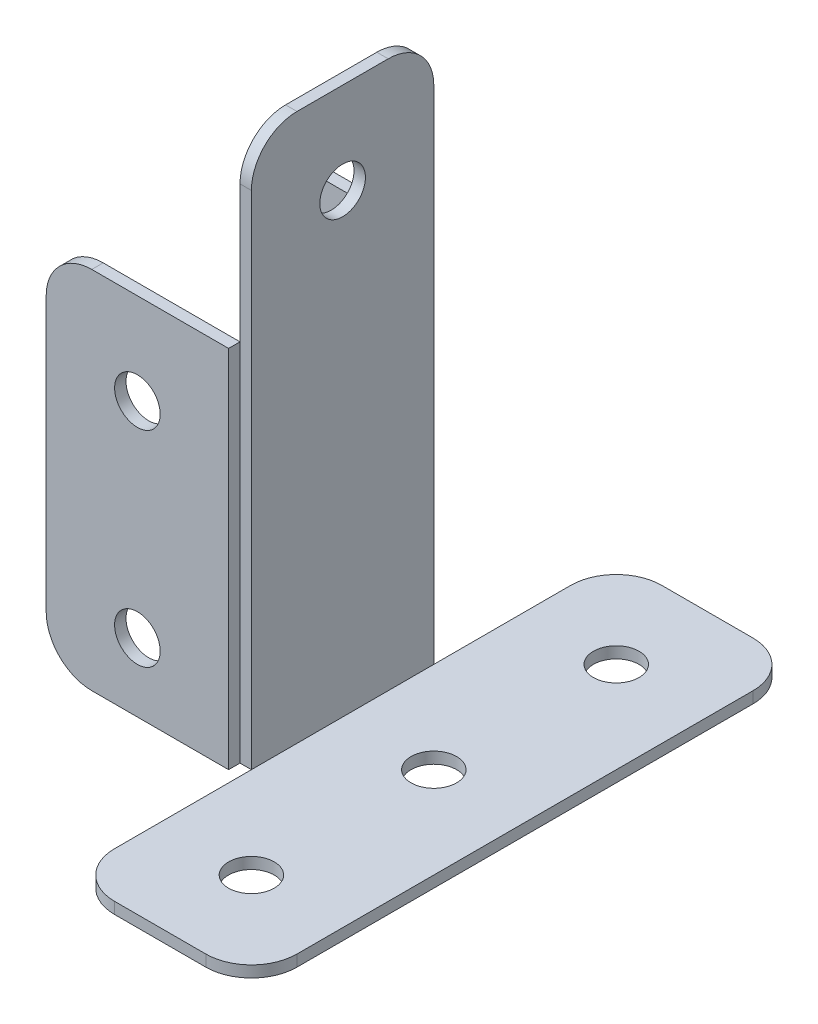
from build123d import *

# Parameters (mm, degrees)
SKETCH1_W           = 25.4
SKETCH1_H           = 50.8
SKETCH1_R           = 3.175
BOSS_EXTRUDE1_DEPTH = 1.5875
BOSS_EXTRUDE2_START = -25.4
SKETCH1_2_W         = 25.4
SKETCH1_2_H         = 50.8
SKETCH1_2_R         = 3.175
BOSS_EXTRUDE2_DEPTH = 1.5875
SKETCH3_R           = 3.175
BOSS_EXTRUDE3_DEPTH = 1.5875
SKETCH4_W           = 25.4
SKETCH4_H           = 76.2
SKETCH4_R           = 3.175
BOSS_EXTRUDE4_DEPTH = 1.5875
FILLET1_R           = 6.35
FILLET2_R           = 6.35
FILLET3_R           = 6.35
FILLET4_R           = 6.35


with BuildPart() as part:
    # Sketch1 → Boss-Extrude1 (new body)
    with BuildSketch(Plane.XY):
        with Locations((-12.7, 25.4)):
            Rectangle(SKETCH1_W, SKETCH1_H)
        with Locations((-12.7, 38.1)):
            Circle(SKETCH1_R, mode=Mode.SUBTRACT)
        with Locations((-12.7, 9.525)):
            Circle(SKETCH1_R, mode=Mode.SUBTRACT)
    extrude(amount=BOSS_EXTRUDE1_DEPTH)

    # Fillet3
    fillet3_edges = [part.edges().sort_by_distance(p)[0] for p in [
        (-25.4, 50.8, 0.79375),
        (-25.4, 0, 0.79375),
    ]]
    fillet(fillet3_edges, radius=FILLET3_R)


with BuildPart() as body_2:
    # Sketch1_2 → Boss-Extrude2 (new body)
    with BuildSketch(Plane.XY.offset(BOSS_EXTRUDE2_START)):
        with Locations((-12.7, 25.4)):
            Rectangle(SKETCH1_2_W, SKETCH1_2_H)
        with Locations((-12.7, 38.1)):
            Circle(SKETCH1_2_R, mode=Mode.SUBTRACT)
        with Locations((-12.7, 9.525)):
            Circle(SKETCH1_2_R, mode=Mode.SUBTRACT)
    extrude(amount=-BOSS_EXTRUDE2_DEPTH)

    # Fillet2
    fillet2_edges = [body_2.edges().sort_by_distance(p)[0] for p in [
        (-25.4, 0, -26.19375),
        (-25.4, 50.8, -26.19375),
    ]]
    fillet(fillet2_edges, radius=FILLET2_R)


with BuildPart() as body_3:
    # Sketch3 → Boss-Extrude3 (new body)
    with BuildSketch(Plane(origin=(0, 0, 0), x_dir=(0, 0, -1), z_dir=(1, 0, 0))):
        Polygon((25.4, 50.8), (25.4, 0), (0, 0), (0, 50.8), (0, 76.2), (25.4, 76.2), align=None)
        with Locations((12.7, 63.5)):
            Circle(SKETCH3_R, mode=Mode.SUBTRACT)
    extrude(amount=BOSS_EXTRUDE3_DEPTH)

    # Fillet4
    fillet4_edges = [body_3.edges().sort_by_distance(p)[0] for p in [
        (0.79375, 76.2, -25.4),
        (0.79375, 76.2, 0),
    ]]
    fillet(fillet4_edges, radius=FILLET4_R)


with BuildPart() as body_4:
    # Sketch4 → Boss-Extrude4 (new body)
    with BuildSketch(Plane(origin=(0, 0, 0), x_dir=(1, 0, 0), z_dir=(0, 1, 0))):
        with Locations((14.2875, 12.7)):
            Rectangle(SKETCH4_W, SKETCH4_H)
        with Locations((14.2875, 38.1)):
            Circle(SKETCH4_R, mode=Mode.SUBTRACT)
        with Locations((14.2875, 12.7)):
            Circle(SKETCH4_R, mode=Mode.SUBTRACT)
        with Locations((14.2875, -12.7)):
            Circle(SKETCH4_R, mode=Mode.SUBTRACT)
    extrude(amount=-BOSS_EXTRUDE4_DEPTH)

    # Fillet1
    fillet1_edges = [body_4.edges().sort_by_distance(p)[0] for p in [
        (1.5875, -0.79375, -50.8),
        (26.9875, -0.79375, -50.8),
        (26.9875, -0.79375, 25.4),
        (1.5875, -0.79375, 25.4),
    ]]
    fillet(fillet1_edges, radius=FILLET1_R)


solid = Compound([part.part, body_2.part, body_3.part, body_4.part])
